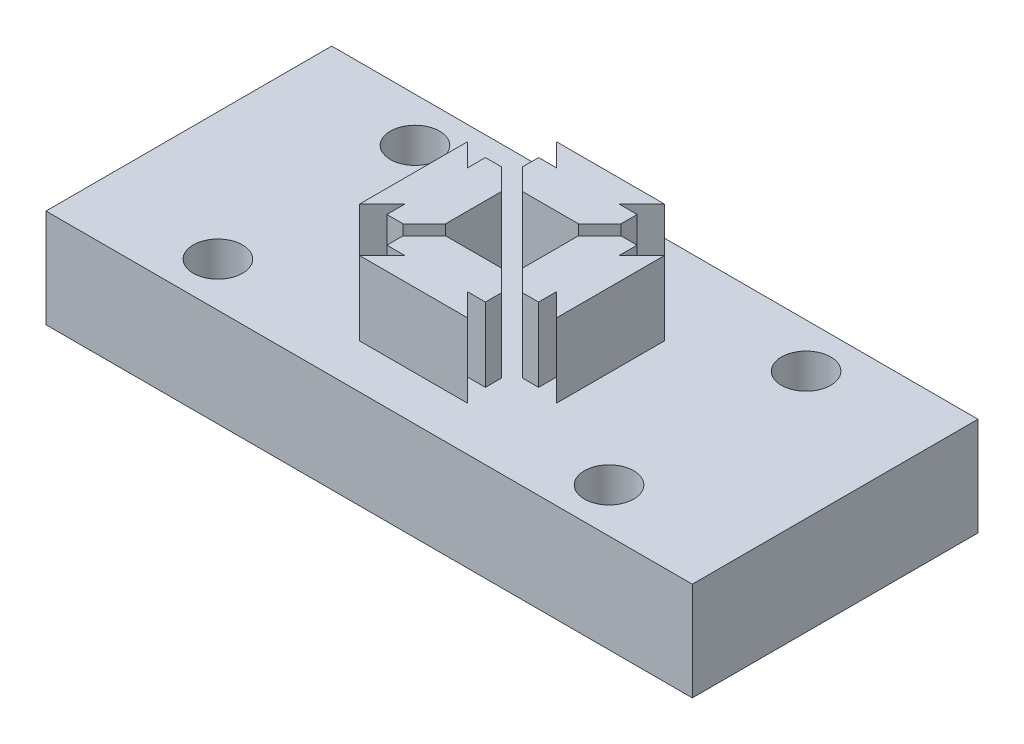
from build123d import *

# Parameters (mm, degrees)
SKETCH1_W           = 65.6
SKETCH1_H           = 29
SKETCH1_R           = 2.5
BOSS_EXTRUDE1_DEPTH = 10
BOSS_EXTRUDE2_DEPTH = 7.5
CIRPATTERN1_COUNT   = 4


with BuildPart() as part:
    # Sketch1 → Boss-Extrude1 (new body)
    with BuildSketch(Plane(origin=(0, 0, 0), x_dir=(1, 0, 0), z_dir=(0, 1, 0))):
        Rectangle(SKETCH1_W, SKETCH1_H)
        with Locations((-19.85, 10)):
            Circle(SKETCH1_R, mode=Mode.SUBTRACT)
        with Locations((19.85, 10)):
            Circle(SKETCH1_R, mode=Mode.SUBTRACT)
        with Locations((19.85, -10)):
            Circle(SKETCH1_R, mode=Mode.SUBTRACT)
        with Locations((-19.85, -10)):
            Circle(SKETCH1_R, mode=Mode.SUBTRACT)
    extrude(amount=BOSS_EXTRUDE1_DEPTH)

    # Sketch2 → Boss-Extrude2 (add)
    with BuildSketch(Plane(origin=(0, 10, 0), x_dir=(1, 0, 0), z_dir=(0, 1, 0))):
        Polygon((-10, 5.5), (-10, -5.5), (-7.7, -3.2), (-7.7, -5), (-6.06, -5), (-3.9, -2.84), (-3.9, 2.84), (-6.06, 5), (-7.7, 5), (-7.7, 3.2), align=None)
    boss_extrude2 = extrude(amount=BOSS_EXTRUDE2_DEPTH)

    # CirPattern1: Boss-Extrude2 ×4 about axis
    cirpattern1_axis = Axis((0, -0.5, 0), (0, 1, 0))
    for i in range(1, CIRPATTERN1_COUNT):
        add(boss_extrude2.rotate(cirpattern1_axis, i * 360 / CIRPATTERN1_COUNT))


solid = part.part
